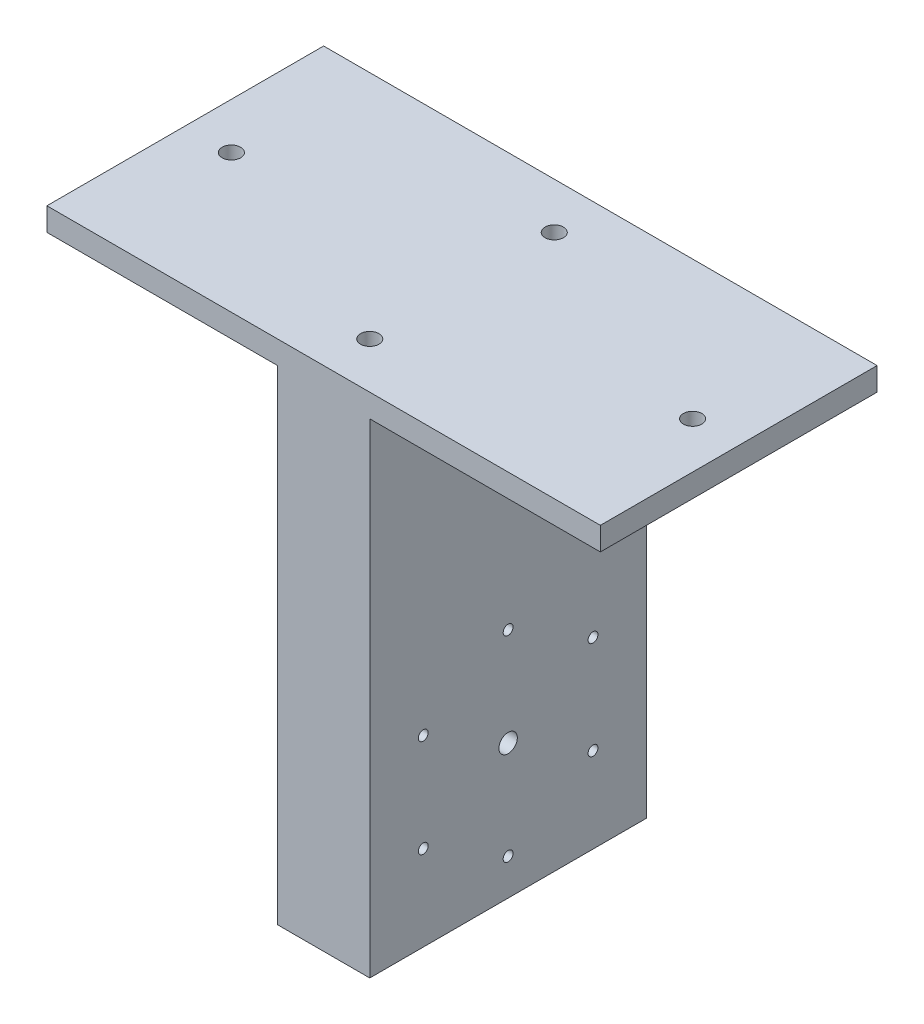
from build123d import *

# Parameters (mm, degrees)
EXTRUDE_1_DEPTH          = 120
SKETCH_2_R               = 4
SKETCH_2_R_2             = 2.139034835
CUT_EXTRUDE_1_DEPTH      = 100
SKETCH_3_R               = 4
CUT_EXTRUDE_2_DEPTH      = 1
CUT_EXTRUDE_2_DEPTH_BACK = 10


with BuildPart() as part:
    # 草图1 → 凸台-拉伸1 (new body)
    with BuildSketch(Plane.XY):
        Polygon((0, 0), (40, 0), (40, 210), (140, 210), (140, 220), (-100, 220), (-100, 210), (0, 210), align=None)
    extrude(amount=EXTRUDE_1_DEPTH)

    # 草图2 → 切除-拉伸1 (cut)
    with BuildSketch(Plane(origin=(40, 0, 0), x_dir=(0, 0, -1), z_dir=(1, 0, 0))):
        with Locations((-60, 58.25)):
            Circle(SKETCH_2_R)
        with Locations((-60, 100.75)):
            Circle(SKETCH_2_R_2)
        with Locations((-23.193920339, 79.5)):
            Circle(SKETCH_2_R_2)
        with Locations((-23.193920339, 37)):
            Circle(SKETCH_2_R_2)
        with Locations((-60, 15.75)):
            Circle(SKETCH_2_R_2)
        with Locations((-96.806079661, 37)):
            Circle(SKETCH_2_R_2)
        with Locations((-96.806079661, 79.5)):
            Circle(SKETCH_2_R_2)
    extrude(amount=-CUT_EXTRUDE_1_DEPTH, mode=Mode.SUBTRACT)

    # 草图3 → 切除-拉伸2 (cut, two sides)
    with BuildSketch(Plane(origin=(0, 220, 0), x_dir=(1, 0, 0), z_dir=(0, 1, 0))) as cut_extrude_2_sk:
        with Locations((-80, -60)):
            Circle(SKETCH_3_R)
        with Locations((20, -20)):
            Circle(SKETCH_3_R)
        with Locations((120, -60)):
            Circle(SKETCH_3_R)
        with Locations((20, -100)):
            Circle(SKETCH_3_R)
    extrude(amount=CUT_EXTRUDE_2_DEPTH, mode=Mode.SUBTRACT)
    extrude(cut_extrude_2_sk.sketch, amount=-CUT_EXTRUDE_2_DEPTH_BACK, mode=Mode.SUBTRACT)


solid = part.part
